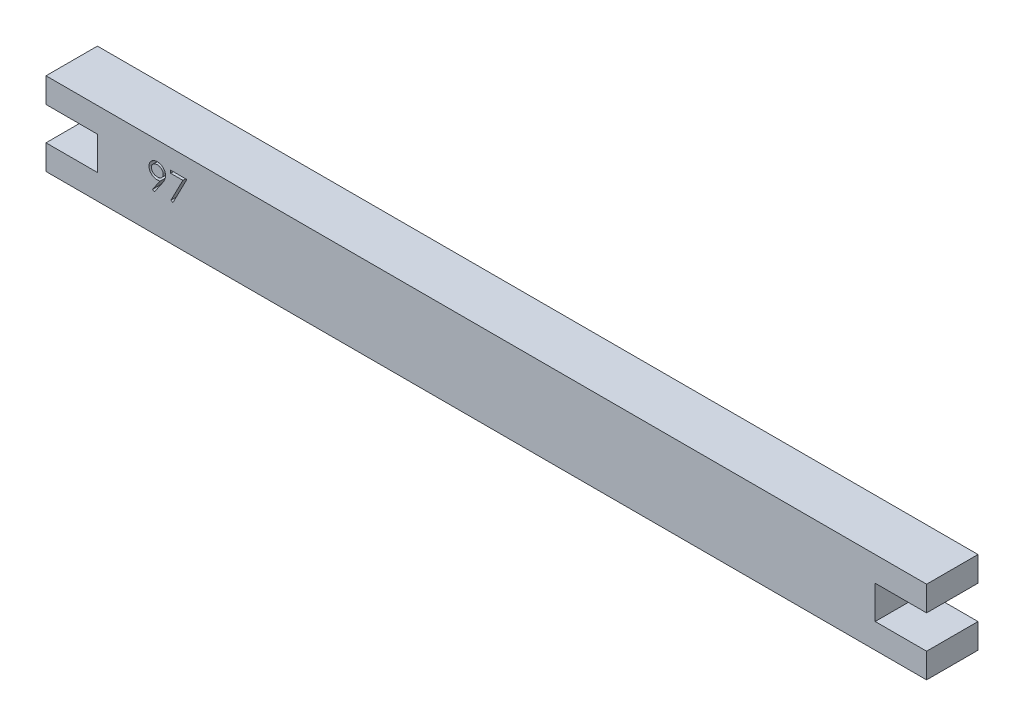
from build123d import *

# Parameters (mm, degrees)
BOSS_EXTRUDE1_DEPTH = 6.2
CUT_EXTRUDE1_DEPTH  = 1


with BuildPart() as part:
    # Sketch1 → Boss-Extrude1 (new body)
    with BuildSketch(Plane.XY):
        Polygon((0, 3), (-6.2, 3), (-6.2, 0), (100, 0), (100, 3), (93.8, 3), (93.8, 7), (100, 7), (100, 10), (-6.2, 10), (-6.2, 7), (0, 7), align=None)
    extrude(amount=BOSS_EXTRUDE1_DEPTH)

    # Sketch2 → Cut-Extrude1 (cut)
    with BuildSketch(Plane.XY.offset(6.2)):
        with BuildLine():
            Line((6.875309832, 4.402369049), (6.647615521, 4.560737438))
            Line((6.647615521, 4.560737438), (7.530407989, 5.851217206))
            add(Edge.make_bspline(
                [(7.530407989, 5.851217206), (7.474082821, 5.844329213), (7.363175427, 5.83076637), (7.251472484, 5.828274762), (7.196498734, 5.827048536)],
                knots=[0, 0, 0, 0, 0.000170115, 0.000334967, 0.000334967, 0.000334967, 0.000334967], degree=3))
            add(Edge.make_bspline(
                [(7.196498734, 5.827048536), (7.163168448, 5.827902227), (7.097744011, 5.829577947), (7.001558154, 5.842860159), (6.909133396, 5.863316346), (6.820714766, 5.893840574), (6.735969929, 5.931775664), (6.655083889, 5.978817383), (6.578165531, 6.034158805), (6.506040952, 6.097507304), (6.440443875, 6.167065252), (6.382002741, 6.240685014), (6.333433285, 6.319221787), (6.293086668, 6.401073486), (6.262488328, 6.487416569), (6.240206598, 6.577268525), (6.226488462, 6.671259086), (6.224856425, 6.735235454), (6.22402778, 6.767718608)],
                knots=[0, 0, 0, 0, 9.9954e-05, 0.000196201, 0.000290782, 0.000383503, 0.000476303, 0.000568919, 0.000663705, 0.000760153, 0.000856434, 0.000950205, 0.001041624, 0.001132931, 0.001223461, 0.001315861, 0.001410305, 0.001507717, 0.001507717, 0.001507717, 0.001507717], degree=3))
            add(Edge.make_bspline(
                [(6.22402778, 6.767718608), (6.225601161, 6.812140172), (6.228689387, 6.89933069), (6.253543756, 7.02672418), (6.294419921, 7.147180545), (6.351414234, 7.260383078), (6.423200731, 7.364703363), (6.509477809, 7.458691172), (6.609720691, 7.541009718), (6.721645809, 7.61177056), (6.842616049, 7.668680165), (6.969315474, 7.710625816), (7.100773283, 7.735298966), (7.189825384, 7.738551854), (7.234659792, 7.740189562)],
                knots=[0, 0, 0, 0, 0.000133185, 0.000261414, 0.000387724, 0.00051373, 0.000640399, 0.00076644, 0.000895188, 0.001028407, 0.001162697, 0.001295241, 0.001427846, 0.0015623, 0.0015623, 0.0015623, 0.0015623], degree=3))
            add(Edge.make_bspline(
                [(7.234659792, 7.740189562), (7.278645715, 7.738529342), (7.365557754, 7.735248905), (7.49336421, 7.711224162), (7.61577499, 7.670732323), (7.732111513, 7.614775612), (7.839825123, 7.544634503), (7.936686037, 7.461055328), (8.020483848, 7.363986028), (8.091081225, 7.255774326), (8.147750476, 7.139508565), (8.188637476, 7.018147435), (8.213806734, 6.892563738), (8.216978402, 6.807478751), (8.218579062, 6.76453852)],
                knots=[0, 0, 0, 0, 0.000131915, 0.000260652, 0.000388569, 0.000517718, 0.000646848, 0.000773094, 0.000900237, 0.001030248, 0.001159674, 0.001287189, 0.001413545, 0.001542287, 0.001542287, 0.001542287, 0.001542287], degree=3))
            add(Edge.make_bspline(
                [(8.218579062, 6.76453852), (8.217510077, 6.731206674), (8.215341908, 6.663601362), (8.200159687, 6.560885266), (8.174378519, 6.456154507), (8.14512162, 6.36750706), (8.116880297, 6.294292966), (8.090299985, 6.236461176), (8.060806817, 6.175590744), (8.02640908, 6.112319945), (7.989431853, 6.045842216), (7.947649509, 5.976824324), (7.902015169, 5.905173652), (7.869512495, 5.856870936), (7.852868926, 5.832136677)],
                knots=[0, 0, 0, 0, 9.9984e-05, 0.000202793, 0.000310776, 0.000423207, 0.000482616, 0.000546097, 0.000614079, 0.0006855, 0.000762103, 0.000842274, 0.000927493, 0.001016928, 0.001016928, 0.001016928, 0.001016928], degree=3))
            Line((7.852868926, 5.832136677), (6.875309832, 4.402369049))
        make_face()
        with BuildLine():
            add(Edge.make_bspline(
                [(7.249288197, 6.152689562), (7.274537624, 6.153379338), (7.323689675, 6.154722099), (7.395696225, 6.162894769), (7.463663181, 6.177385456), (7.5277721, 6.198176909), (7.588665789, 6.223265459), (7.64537703, 6.25520776), (7.697953284, 6.293322851), (7.746746618, 6.336149079), (7.790075389, 6.383729251), (7.828667995, 6.43352877), (7.861470796, 6.485766237), (7.887381769, 6.541095839), (7.908685633, 6.598170736), (7.923397687, 6.657910044), (7.931547761, 6.720002521), (7.932937118, 6.762183447), (7.933643165, 6.783619049)],
                knots=[0, 0, 0, 0, 7.5753e-05, 0.000147465, 0.000217073, 0.000283852, 0.000349411, 0.000414338, 0.000478589, 0.000543925, 0.000608743, 0.000671332, 0.000732749, 0.000793345, 0.000854313, 0.000915245, 0.00097749, 0.001041807, 0.001041807, 0.001041807, 0.001041807], degree=3))
            add(Edge.make_bspline(
                [(7.933643165, 6.783619049), (7.933035679, 6.805063602), (7.931838555, 6.847322725), (7.922234361, 6.909507132), (7.905338623, 6.969100305), (7.882668683, 7.026428495), (7.852805325, 7.081020689), (7.81697002, 7.133562287), (7.774395583, 7.183720146), (7.725407541, 7.230314617), (7.672580482, 7.273265925), (7.616282743, 7.311171866), (7.556978355, 7.342941094), (7.495029125, 7.369156588), (7.43030598, 7.38961427), (7.362847219, 7.404325737), (7.292311958, 7.4124644), (7.244431791, 7.413844975), (7.220031386, 7.414548536)],
                knots=[0, 0, 0, 0, 6.4316e-05, 0.000126743, 0.000188161, 0.000249812, 0.000311283, 0.000374438, 0.00044032, 0.000508243, 0.00057698, 0.000644365, 0.000711521, 0.0007785, 0.000845884, 0.000914871, 0.00098532, 0.001058531, 0.001058531, 0.001058531, 0.001058531], degree=3))
            add(Edge.make_bspline(
                [(7.220031386, 7.414548536), (7.19584319, 7.413843839), (7.148386148, 7.412461228), (7.078477946, 7.404341207), (7.011475315, 7.389515332), (6.946939703, 7.369166064), (6.884992313, 7.342939138), (6.825690722, 7.311170201), (6.769379814, 7.273274651), (6.716603403, 7.230280821), (6.66752886, 7.183937028), (6.625686416, 7.133342561), (6.589769099, 7.08104802), (6.559946775, 7.026421231), (6.53726592, 6.969102243), (6.520373105, 6.909506607), (6.510768126, 6.847322862), (6.509571109, 6.805063648), (6.508963678, 6.783619049)],
                knots=[0, 0, 0, 0, 7.2576e-05, 0.000142393, 0.000210758, 0.000278143, 0.000345121, 0.000412278, 0.000479663, 0.0005484, 0.000616323, 0.000681795, 0.00074495, 0.000806421, 0.000868072, 0.00092949, 0.000991917, 0.001056233, 0.001056233, 0.001056233, 0.001056233], degree=3))
            add(Edge.make_bspline(
                [(6.508963678, 6.783619049), (6.509513339, 6.762166754), (6.510597373, 6.719858903), (6.521054725, 6.657695675), (6.538542879, 6.598107099), (6.561964754, 6.540513772), (6.592809054, 6.48547573), (6.630658545, 6.433253908), (6.675022861, 6.383256321), (6.725308954, 6.336259779), (6.780343643, 6.293123163), (6.839123548, 6.255449173), (6.900636757, 6.223633456), (6.965099808, 6.198105201), (7.032034976, 6.177593192), (7.102043846, 6.162921475), (7.17489489, 6.154800491), (7.224252516, 6.153399956), (7.249288197, 6.152689562)],
                knots=[0, 0, 0, 0, 6.4316e-05, 0.000126844, 0.000188436, 0.000250326, 0.000312966, 0.000377217, 0.000443451, 0.000513196, 0.000583426, 0.000652939, 0.000722346, 0.000790847, 0.000860662, 0.000932137, 0.001005113, 0.00108023, 0.00108023, 0.00108023, 0.00108023], degree=3))
        make_face(mode=Mode.SUBTRACT)
        Polygon((8.829155986, 7.658779305), (10.783002139, 7.658779305), (9.114091883, 4.402369049), (8.867953061, 4.537840804), (10.300900777, 7.33313828), (8.829155986, 7.33313828), align=None)
    extrude(amount=-CUT_EXTRUDE1_DEPTH, mode=Mode.SUBTRACT)


solid = part.part
